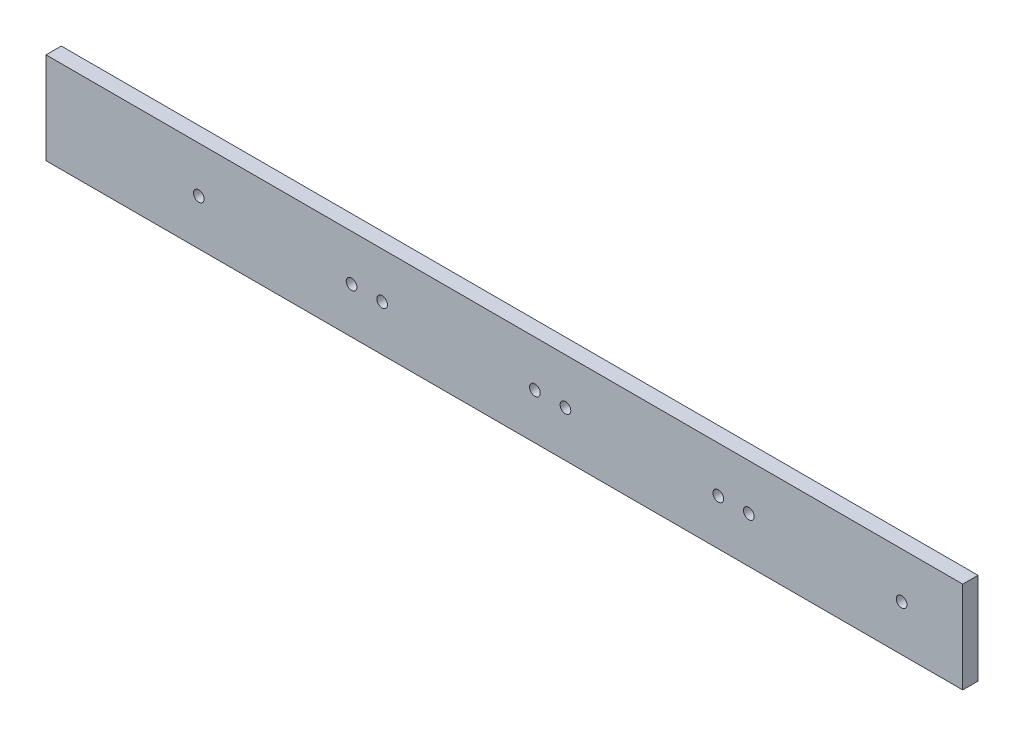
from build123d import *

# Parameters (mm, degrees)
SKETCH1_W           = 300
SKETCH1_H           = 30
BOSS_EXTRUDE1_DEPTH = 5
SKETCH2_R           = 1.75
CUT_EXTRUDE1_DEPTH  = 6


with BuildPart() as part:
    # Sketch1 → Boss-Extrude1 (new body)
    with BuildSketch(Plane.XY):
        with Locations((150, 15)):
            Rectangle(SKETCH1_W, SKETCH1_H)
    extrude(amount=BOSS_EXTRUDE1_DEPTH)

    # Sketch2 → Cut-Extrude1 (cut, through all)
    with BuildSketch(Plane.XY.offset(5)):
        with Locations((280, 15)):
            Circle(SKETCH2_R)
        with Locations((230, 15)):
            Circle(SKETCH2_R)
        with Locations((170, 15)):
            Circle(SKETCH2_R)
        with Locations((220, 15)):
            Circle(SKETCH2_R)
        with Locations((110, 15)):
            Circle(SKETCH2_R)
        with Locations((160, 15)):
            Circle(SKETCH2_R)
        with Locations((50, 15)):
            Circle(SKETCH2_R)
        with Locations((100, 15)):
            Circle(SKETCH2_R)
    extrude(amount=-CUT_EXTRUDE1_DEPTH, mode=Mode.SUBTRACT)


solid = part.part
